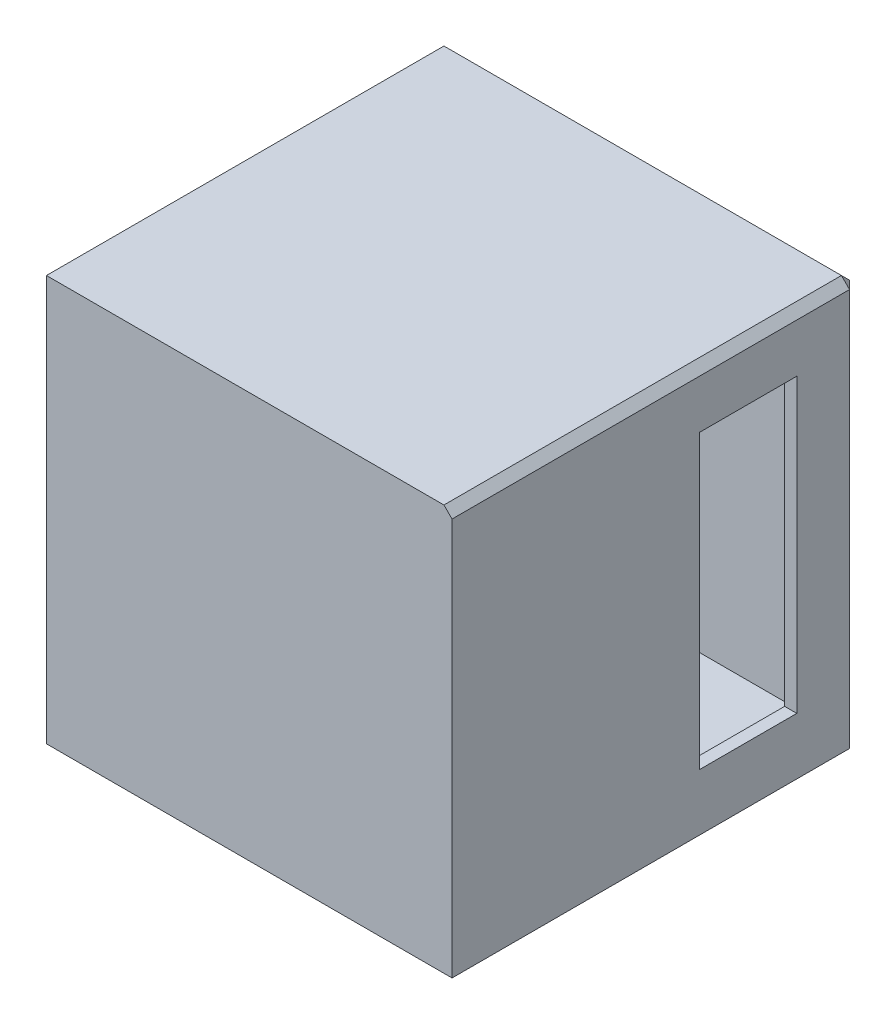
from build123d import *

# Parameters (mm, degrees)
ESQUISSE1_W             = 100
ESQUISSE1_H             = 100
BOSS_EXTRU_1_DEPTH      = 3
ESQUISSE2_W             = 100
ESQUISSE2_H             = 100
ESQUISSE2_W_2           = 94
ESQUISSE2_H_2           = 94
BOSS_EXTRU_2_DEPTH      = 94
ESQUISSE3_W             = 100
ESQUISSE3_H             = 100
BOSS_EXTRU_3_DEPTH      = 3
ESQUISSE4_W             = 24
ESQUISSE4_H             = 72
ENL_V_MAT_EXTRU_1_DEPTH = 3
CHANFREIN1_SIZE         = 2


with BuildPart() as part:
    # Esquisse1 → Boss.-Extru.1 (new body)
    with BuildSketch(Plane.XY):
        with Locations((50, 50)):
            Rectangle(ESQUISSE1_W, ESQUISSE1_H)
    extrude(amount=BOSS_EXTRU_1_DEPTH)

    # Esquisse2 → Boss.-Extru.2 (add)
    with BuildSketch(Plane.XY.offset(3)):
        with Locations((50, 50)):
            Rectangle(ESQUISSE2_W, ESQUISSE2_H)
        with Locations((50, 50)):
            Rectangle(ESQUISSE2_W_2, ESQUISSE2_H_2, mode=Mode.SUBTRACT)
    extrude(amount=BOSS_EXTRU_2_DEPTH)

    # Esquisse3 → Boss.-Extru.3 (add)
    with BuildSketch(Plane.XY.offset(97)):
        with Locations((50, 50)):
            Rectangle(ESQUISSE3_W, ESQUISSE3_H)
    extrude(amount=BOSS_EXTRU_3_DEPTH)

    # Esquisse4 → Enlèv. mat.-Extru.1 (cut)
    with BuildSketch(Plane(origin=(100, 0, 0), x_dir=(0, 0, -1), z_dir=(1, 0, 0))):
        with Locations((-27, 50)):
            Rectangle(ESQUISSE4_W, ESQUISSE4_H)
    extrude(amount=-ENL_V_MAT_EXTRU_1_DEPTH, mode=Mode.SUBTRACT)

    # Chanfrein1
    chanfrein1_edges = [part.edges().sort_by_distance(p)[0] for p in [
        (50, 100, 0),
        (100, 50, 0),
        (100, 100, 50),
    ]]
    chamfer(chanfrein1_edges, length=CHANFREIN1_SIZE)


solid = part.part
